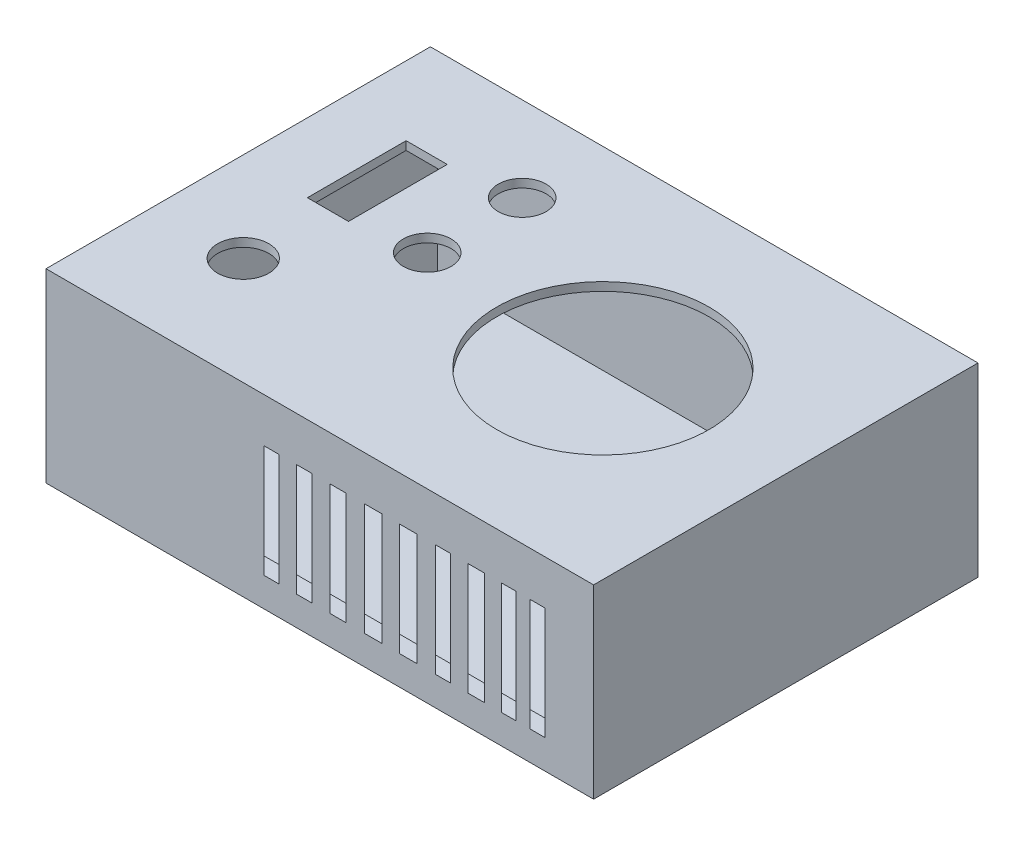
from build123d import *

# Parameters (mm, degrees)
SKETCH1_W           = 164.845307866
SKETCH1_H           = 115.711925012
SKETCH1_W_2         = 150.387290324
SKETCH1_H_2         = 105.563228254
BOSS_EXTRUDE1_DEPTH = 2.54
SKETCH1_3_W         = 164.845307866
SKETCH1_3_H         = 115.711925012
SKETCH1_3_W_2       = 150.387290324
SKETCH1_3_H_2       = 105.563228254
BOSS_EXTRUDE2_DEPTH = 53.34
BOSS_EXTRUDE3_START = 53.34
SKETCH1_4_W         = 164.845307866
SKETCH1_4_H         = 115.711925012
SKETCH1_4_W_2       = 150.387290324
SKETCH1_4_H_2       = 105.563228254
BOSS_EXTRUDE3_DEPTH = 2.54
SKETCH2_R           = 31.968042231
SKETCH2_R_2         = 7.197604608
SKETCH2_R_3         = 7.702224934
SKETCH2_W           = 12.372659968
SKETCH2_H           = 29.724433098
CUT_EXTRUDE1_DEPTH  = 2.54
SKETCH3_W           = 4.472305678
SKETCH3_H           = 33.780947159
SKETCH3_W_2         = 4.478852124
SKETCH3_W_3         = 5.014326271
SKETCH3_W_4         = 5.285336568
SKETCH3_W_5         = 5.288609791
SKETCH3_W_6         = 4.762955313
SKETCH3_W_7         = 4.703323858
SKETCH3_W_8         = 4.457199363
CUT_EXTRUDE2_DEPTH  = 81.820687539


with BuildPart() as part:
    # Sketch1 → Boss-Extrude1 (new body)
    with BuildSketch(Plane(origin=(0, 0, 0), x_dir=(1, 0, 0), z_dir=(0, 1, 0))):
        Rectangle(SKETCH1_W, SKETCH1_H)
        Rectangle(SKETCH1_W_2, SKETCH1_H_2, mode=Mode.SUBTRACT)
        Rectangle(SKETCH1_W_2, SKETCH1_H_2)
    extrude(amount=BOSS_EXTRUDE1_DEPTH)

    # Sketch1_3 → Boss-Extrude2 (add)
    with BuildSketch(Plane(origin=(0, 0, 0), x_dir=(1, 0, 0), z_dir=(0, 1, 0))):
        Rectangle(SKETCH1_3_W, SKETCH1_3_H)
        Rectangle(SKETCH1_3_W_2, SKETCH1_3_H_2, mode=Mode.SUBTRACT)
    extrude(amount=BOSS_EXTRUDE2_DEPTH)

    # Sketch1_4 → Boss-Extrude3 (add)
    with BuildSketch(Plane(origin=(0, 0, 0), x_dir=(1, 0, 0), z_dir=(0, 1, 0)).offset(BOSS_EXTRUDE3_START)):
        Rectangle(SKETCH1_4_W, SKETCH1_4_H)
        Rectangle(SKETCH1_4_W_2, SKETCH1_4_H_2, mode=Mode.SUBTRACT)
        Rectangle(SKETCH1_4_W_2, SKETCH1_4_H_2)
    extrude(amount=BOSS_EXTRUDE3_DEPTH)

    # Sketch2 → Cut-Extrude1 (cut)
    with BuildSketch(Plane(origin=(0, 55.88, 0), x_dir=(1, 0, 0), z_dir=(0, 1, 0))):
        with Locations(Location((27.35736774, 0, 0), (0, 0, 270))):
            Circle(SKETCH2_R)
        with Locations(Location((-29.22455859, 32.289622442, 0), (0, 0, 270))):
            Circle(SKETCH2_R_2)
        with Locations(Location((-29.22455859, 3.70269924, 0), (0, 0, 270))):
            Circle(SKETCH2_R_2)
        with Locations(Location((-55.407149161, -25.489564673, 0), (0, 0, 270))):
            Circle(SKETCH2_R_3)
        with Locations((-55.407149161, 14.862216549)):
            Rectangle(SKETCH2_W, SKETCH2_H)
    extrude(amount=-CUT_EXTRUDE1_DEPTH, mode=Mode.SUBTRACT)

    # Sketch3 → Cut-Extrude2 (cut, along a direction that is not the sketch's normal)
    with BuildSketch(Plane.XY.offset(57.855962506)):
        with Locations((65.530463392, 25.643218911)):
            Rectangle(SKETCH3_W, SKETCH3_H)
        with Locations((56.86140712, 25.643218911)):
            Rectangle(SKETCH3_W_2, SKETCH3_H)
        with Locations((47.101763215, 25.643218911)):
            Rectangle(SKETCH3_W_3, SKETCH3_H)
        with Locations((37.06783579, 25.643218911)):
            Rectangle(SKETCH3_W_2, SKETCH3_H)
        with Locations((26.637212589, 25.643218911)):
            Rectangle(SKETCH3_W_4, SKETCH3_H)
        with Locations((16.066174405, 25.643218911)):
            Rectangle(SKETCH3_W_5, SKETCH3_H)
        with Locations((5.491862999, 25.643218911)):
            Rectangle(SKETCH3_W_6, SKETCH3_H)
        with Locations((-4.645950069, 25.643218911)):
            Rectangle(SKETCH3_W_7, SKETCH3_H)
        with Locations((-14.58703369, 25.643218911)):
            Rectangle(SKETCH3_W_8, SKETCH3_H)
    extrude(amount=-CUT_EXTRUDE2_DEPTH, dir=(0.7071067811865475, 0, 0.7071067811865477), mode=Mode.SUBTRACT)


solid = part.part
